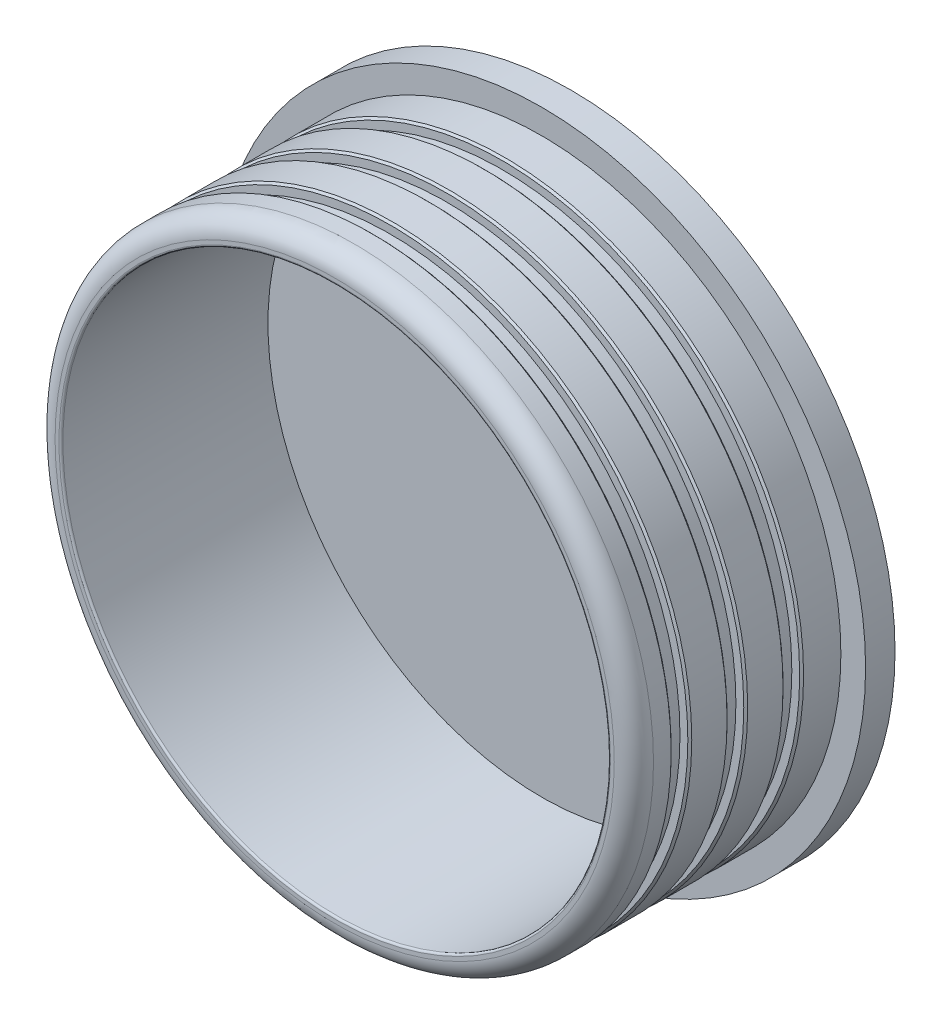
from build123d import *

# Parameters (mm, degrees)
CHAMFER1_SIZE = 0.5
FILLET1_R     = 5
FILLET2_R     = 0.5


with BuildPart() as part:
    # Sketch1 → Revolve1 (revolve)
    with BuildSketch(Plane(origin=(0, 0, 0), x_dir=(1, 0, 0), z_dir=(0, 1, 0))):
        Polygon((69.75, 0), (76.25, 0), (76.25, 10), (73.75, 10), (73.75, 14.25), (76.25, 14.25), (76.25, 24.25), (73.75, 24.25), (73.75, 28.5), (76.25, 28.5), (76.25, 38.5), (73.75, 38.5), (73.75, 42.75), (76.25, 42.75), (76.25, 52.75), (82.55, 52.75), (82.55, 60.25), (0, 60.25), (0, 52.75), (69.75, 52.75), align=None)
    revolve(axis=Axis((0, 0, 0), (0, 0, -1)))

    # Chamfer1
    chamfer1_edges = [part.edges().sort_by_distance(p)[0] for p in [
        (-76.25, 0, -14.25),
        (-76.25, 0, -24.25),
        (-76.25, 0, -28.5),
        (-76.25, 0, -38.5),
        (-76.25, 0, -42.75),
        (-76.25, 0, -10),
    ]]
    chamfer(chamfer1_edges, length=CHAMFER1_SIZE)

    # Fillet1
    fillet1_edges = [part.edges().sort_by_distance(p)[0] for p in [
        (-76.25, 0, 0),
    ]]
    fillet(fillet1_edges, radius=FILLET1_R)

    # Fillet2
    fillet2_edges = [part.edges().sort_by_distance(p)[0] for p in [
        (-69.75, 0, 0),
    ]]
    fillet(fillet2_edges, radius=FILLET2_R)


solid = part.part
